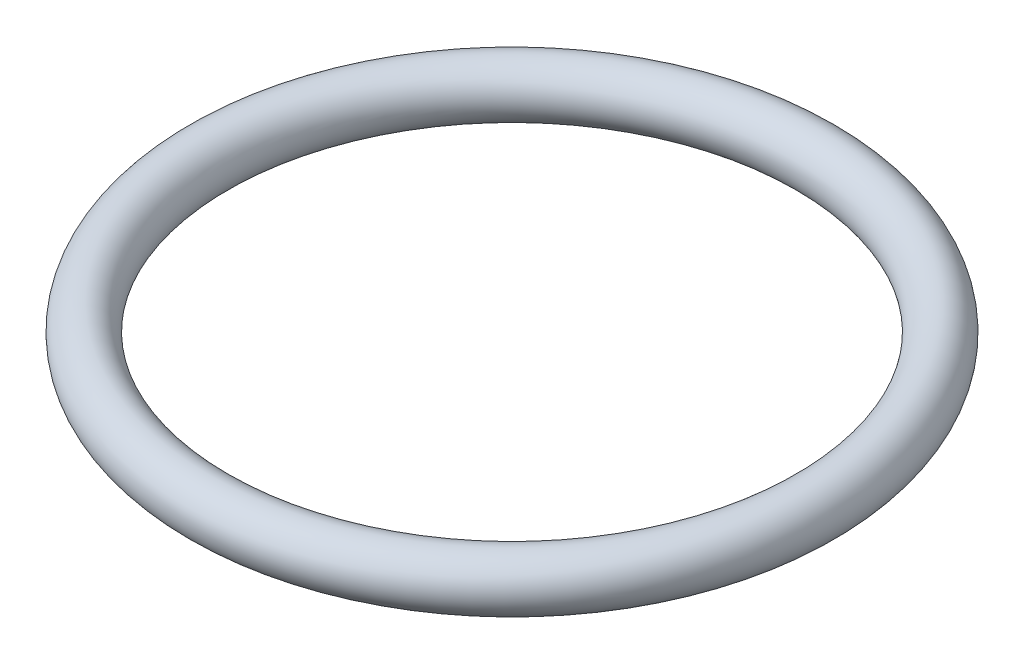
from build123d import *

# Parameters (mm, degrees)
SKETCH1_R = 1.5


with BuildPart() as part:
    # Sketch1 → Revolve1 (revolve)
    with BuildSketch(Plane.XY):
        with Locations((-17, 0)):
            Circle(SKETCH1_R)
    revolve(axis=Axis((0, 3.168228301, 0), (0, -1, 0)))


solid = part.part
